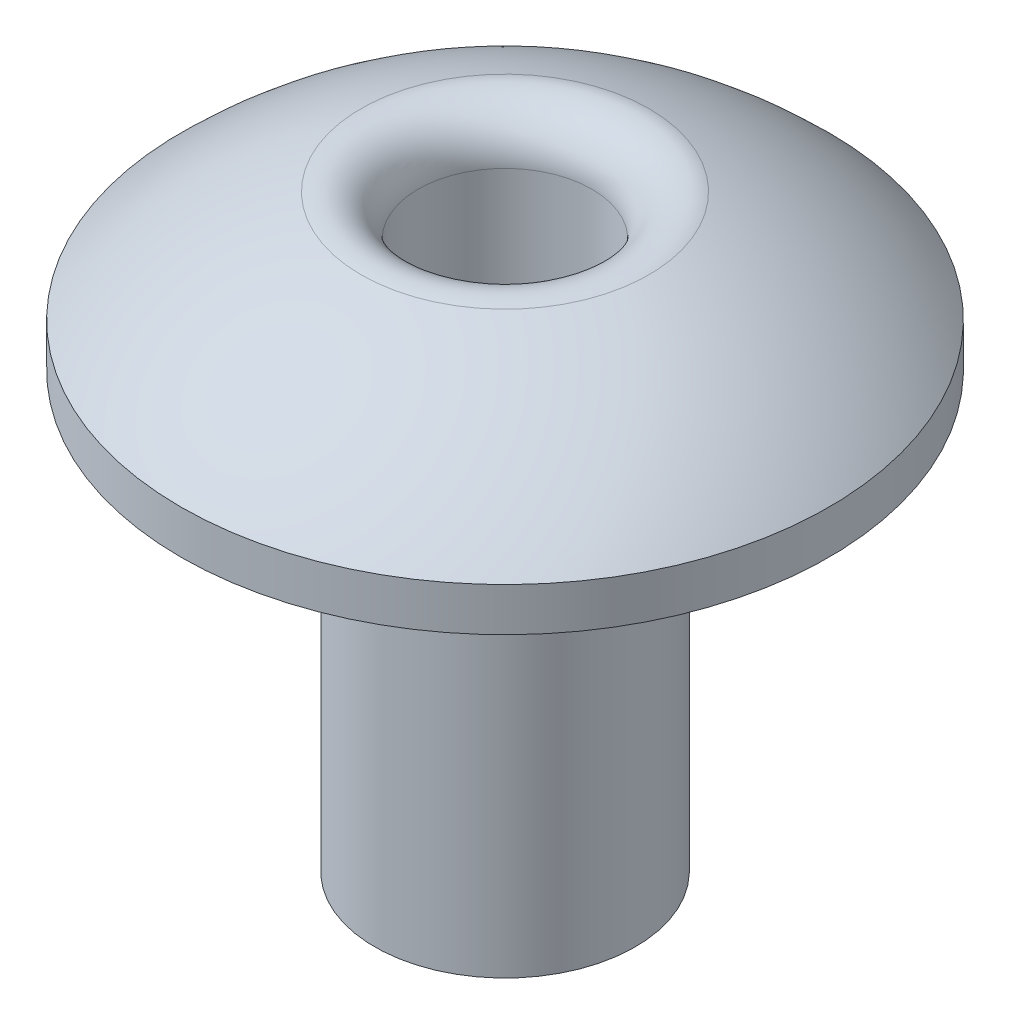
from build123d import *

# Parameters (mm, degrees)
SKETCH3_R           = 1.5
BOSS_EXTRUDE1_DEPTH = 5
SKETCH4_R           = 1
CUT_EXTRUDE1_DEPTH  = 8.04531685
FILLET1_R           = 0.5
SCALE_1_SCALE       = 0.894736842


with BuildPart() as part:
    # Sketch2 → Revolve2 (revolve)
    with BuildSketch(Plane(origin=(0, 0, 0), x_dir=(0, 0, -1), z_dir=(1, 0, 0))):
        with BuildLine():
            Line((0, 1.54531685), (0, 0))
            Line((0, 0), (0, -0.5))
            Line((0, -0.5), (-3.730724896, -0.5))
            Line((-3.730724896, -0.5), (-3.730724896, 0))
            ThreePointArc((-3.730724896, 0), (-2.019053765, 1.143702085), (0, 1.54531685))
        make_face()
    revolve(axis=Axis((0, -0.5, 0), (0, 1, 0)))

    # Sketch3 → Boss-Extrude1 (add)
    with BuildSketch(Plane.XZ.offset(0.5)):
        Circle(SKETCH3_R)
    extrude(amount=BOSS_EXTRUDE1_DEPTH)

    # Sketch4 → Cut-Extrude1 (cut, through all)
    with BuildSketch(Plane.XZ.offset(5.5)):
        Circle(SKETCH4_R)
    extrude(amount=-CUT_EXTRUDE1_DEPTH, mode=Mode.SUBTRACT)

    # Fillet1
    fillet1_edges = [part.edges().sort_by_distance(p)[0] for p in [
        (-0.707106781, 1.449682086, -0.707106781),
    ]]
    fillet(fillet1_edges, radius=FILLET1_R)


with BuildPart() as part_1:
    # ｽｹｰﾙ1: scaled about (5.91e-07, -0.705292116, -1.889e-06)
    add(part.part.scale(SCALE_1_SCALE).moved(Location((6.2e-08, -0.074241275, -1.99e-07))))


solid = part_1.part
